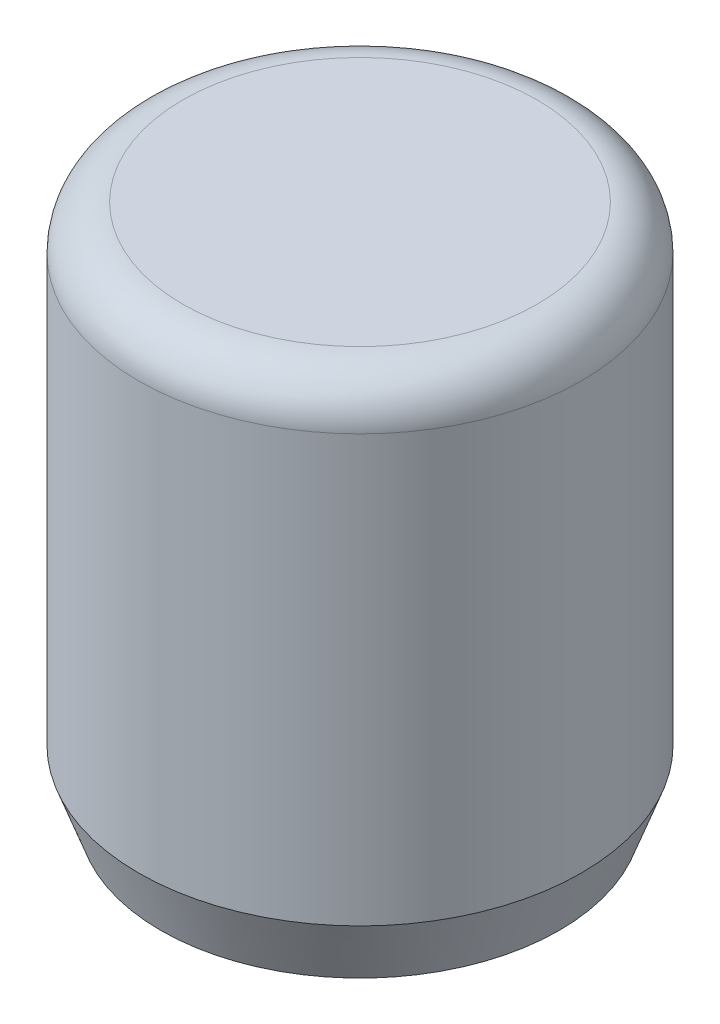
from build123d import *

# Parameters (mm, degrees)
SKETCH1_R           = 5
BOSS_EXTRUDE1_DEPTH = 12
SKETCH2_R           = 3
CUT_EXTRUDE1_DEPTH  = 6
FILLET1_R           = 1
CHAMFER1_SIZE       = 0.5
CHAMFER1_SIZE2      = 1.37373871


with BuildPart() as part:
    # Sketch1 → Boss-Extrude1 (new body)
    with BuildSketch(Plane(origin=(0, 0, 0), x_dir=(1, 0, 0), z_dir=(0, 1, 0))):
        Circle(SKETCH1_R)
    extrude(amount=BOSS_EXTRUDE1_DEPTH)

    # Sketch2 → Cut-Extrude1 (cut)
    with BuildSketch(Plane.XZ):
        Circle(SKETCH2_R)
    extrude(amount=-CUT_EXTRUDE1_DEPTH, mode=Mode.SUBTRACT)

    # Fillet1
    fillet1_edges = [part.edges().sort_by_distance(p)[0] for p in [
        (-5, 12, 0),
    ]]
    fillet(fillet1_edges, radius=FILLET1_R)

    # Chamfer1
    chamfer1_edges = [part.edges().sort_by_distance(p)[0] for p in [
        (-5, 0, 0),
    ]]
    chamfer1_side = [part.faces().sort_by_distance(p)[0] for p in [
        (-4.858578644, 0, 0),
    ]]
    chamfer(chamfer1_edges, length=CHAMFER1_SIZE, length2=CHAMFER1_SIZE2, reference=chamfer1_side[0])


solid = part.part
